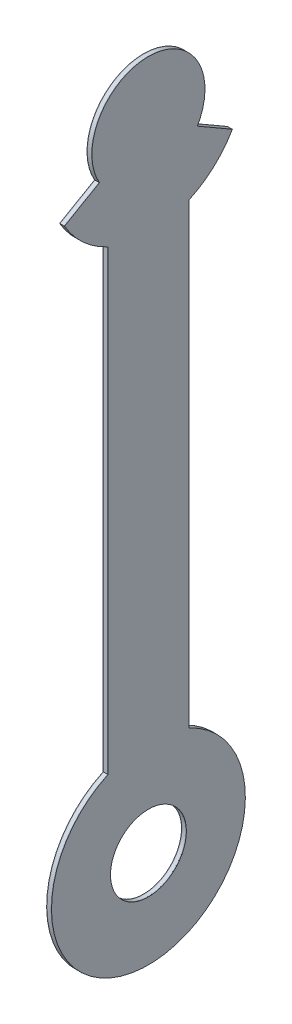
from build123d import *

# Parameters (mm, degrees)
SKETCH1_R           = 35
SKETCH1_R_2         = 60
SKETCH1_R_3         = 23.5
BOSS_EXTRUDE1_DEPTH = 0.25
SKETCH2_R           = 23.5
BOSS_EXTRUDE2_DEPTH = 2.5
SKETCH4_R           = 23.5
BOSS_EXTRUDE3_DEPTH = 0.25


with BuildPart() as part:
    # Sketch1 → Boss-Extrude1 (new body)
    with BuildSketch(Plane(origin=(0, 0, 0), x_dir=(0, 0, -1), z_dir=(1, 0, 0))):
        Circle(SKETCH1_R)
        with BuildLine():
            ThreePointArc((30.310889132, -17.5), (0, -35), (-30.310889132, -17.5))
            Line((-30.310889132, -17.5), (-51.961524227, -30))
            ThreePointArc((-51.961524227, -30), (-40.390167668, -44.369295191), (-25, -54.543560573))
            ThreePointArc((-25, -54.543560573), (0, -60), (25, -54.543560573))
            ThreePointArc((25, -54.543560573), (40.390167668, -44.369295191), (51.961524227, -30))
            Line((51.961524227, -30), (30.310889132, -17.5))
        make_face()
        with BuildLine():
            ThreePointArc((25, -54.543560573), (0, -60), (-25, -54.543560573))
            Line((-25, -54.543560573), (-25, -337.456439427))
            ThreePointArc((-25, -337.456439427), (0, -332), (25, -337.456439427))
            Line((25, -337.456439427), (25, -54.543560573))
        make_face()
        with Locations((0, -392)):
            Circle(SKETCH1_R_2)
        with Locations((0, -392)):
            Circle(SKETCH1_R_3, mode=Mode.SUBTRACT)
    extrude(amount=-BOSS_EXTRUDE1_DEPTH)


with BuildPart() as body_2:
    # Sketch2 → Boss-Extrude2 (new body)
    with BuildSketch(Plane.ZY.offset(0.25)):
        with BuildLine():
            Line((-30.310889132, -17.5), (-51.961524227, -30))
            ThreePointArc((-51.961524227, -30), (-40.390167668, -44.369295191), (-25, -54.543560573))
            Line((-25, -54.543560573), (-25, -337.456439427))
            ThreePointArc((-25, -337.456439427), (0, -452), (25, -337.456439427))
            Line((25, -337.456439427), (25, -54.543560573))
            ThreePointArc((25, -54.543560573), (40.390167668, -44.369295191), (51.961524227, -30))
            Line((51.961524227, -30), (30.310889132, -17.5))
            ThreePointArc((30.310889132, -17.5), (0, 35), (-30.310889132, -17.5))
        make_face()
        with Locations((0, -392)):
            Circle(SKETCH2_R, mode=Mode.SUBTRACT)
    extrude(amount=BOSS_EXTRUDE2_DEPTH)


with BuildPart() as body_3:
    # Sketch4 → Boss-Extrude3 (new body)
    with BuildSketch(Plane.ZY.offset(2.75)):
        with BuildLine():
            Line((51.961524227, -30), (30.310889132, -17.5))
            ThreePointArc((30.310889132, -17.5), (0, 35), (-30.310889132, -17.5))
            Line((-30.310889132, -17.5), (-51.961524227, -30))
            ThreePointArc((-51.961524227, -30), (-40.390167668, -44.369295191), (-25, -54.543560573))
            Line((-25, -54.543560573), (-25, -337.456439427))
            ThreePointArc((-25, -337.456439427), (0, -452), (25, -337.456439427))
            Line((25, -337.456439427), (25, -54.543560573))
            ThreePointArc((25, -54.543560573), (40.390167668, -44.369295191), (51.961524227, -30))
        make_face()
        with Locations((0, -392)):
            Circle(SKETCH4_R, mode=Mode.SUBTRACT)
    extrude(amount=BOSS_EXTRUDE3_DEPTH)


solid = Compound([part.part, body_2.part, body_3.part])
